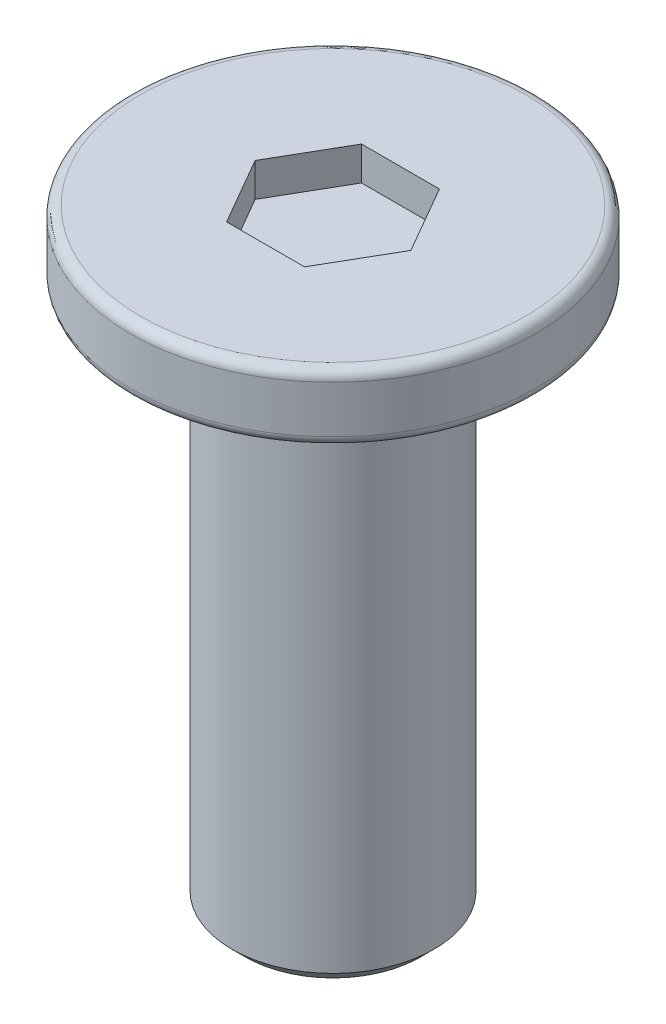
from build123d import *

# Parameters (mm, degrees)
SKETCH_1_R          = 3
EXTRUDE_1_DEPTH     = 1
SKETCH_2_R          = 1.5
EXTRUDE_2_DEPTH     = 8
FILLET_1_R          = 0.15
CHAMFER_1_SIZE      = 0.2
CUT_EXTRUDE_1_DEPTH = 0.5


with BuildPart() as part:
    # 草图1 → 凸台-拉伸1 (new body)
    with BuildSketch(Plane(origin=(0, 0, 0), x_dir=(1, 0, 0), z_dir=(0, 1, 0))):
        Circle(SKETCH_1_R)
    extrude(amount=EXTRUDE_1_DEPTH)

    # 草图2 → 凸台-拉伸2 (add)
    with BuildSketch(Plane.XZ):
        Circle(SKETCH_2_R)
    extrude(amount=EXTRUDE_2_DEPTH)

    # 圆角1
    fillet_1_edges = [part.edges().sort_by_distance(p)[0] for p in [
        (-3, 0, 0),
        (-3, 1, 0),
    ]]
    fillet(fillet_1_edges, radius=FILLET_1_R)

    # 倒角1
    chamfer_1_edges = [part.edges().sort_by_distance(p)[0] for p in [
        (-1.5, -8, 0),
    ]]
    chamfer(chamfer_1_edges, length=CHAMFER_1_SIZE)

    # 草图3 → 切除-拉伸1 (cut)
    with BuildSketch(Plane(origin=(0, 1, 0), x_dir=(1, 0, 0), z_dir=(0, 1, 0))):
        Polygon((1.154700538, 0), (0.577350269, 1), (-0.577350269, 1), (-1.154700538, 0), (-0.577350269, -1), (0.577350269, -1), align=None)
    extrude(amount=-CUT_EXTRUDE_1_DEPTH, mode=Mode.SUBTRACT)


solid = part.part
